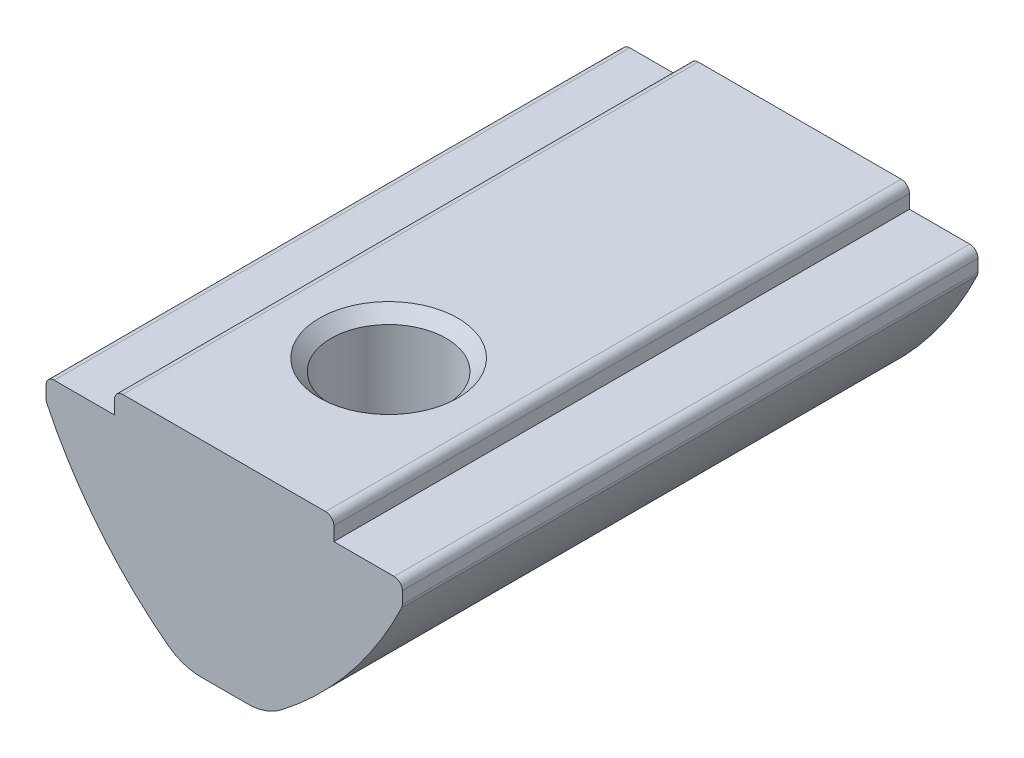
from build123d import *

# Parameters (mm, degrees)
EXTRUDE_1_DEPTH             = 10.5
FILLET_1_R                  = 0.3
FILLET_2_R                  = 2
HOLE_WIZARD_M52_D           = 4.2
HOLE_WIZARD_M52_CSINK_D     = 5.05
HOLE_WIZARD_M52_CSINK_ANGLE = 90


with BuildPart() as part:
    # Эскиз1 → Бобышка-Вытянуть1 (new body, symmetric)
    with BuildSketch(Plane.XY):
        with BuildLine():
            Line((-4, 0), (4, 0))
            Line((4, 0), (4, -0.8))
            Line((4, -0.8), (6.5, -0.8))
            Line((6.5, -0.8), (6.5, -1.6))
            ThreePointArc((6.5, -1.6), (4.386776199, -4.87777644), (1.5, -7.5))
            Line((1.5, -7.5), (-1.5, -7.5))
            ThreePointArc((-1.5, -7.5), (-4.386776199, -4.87777644), (-6.5, -1.6))
            Line((-6.5, -1.6), (-6.5, -0.8))
            Line((-6.5, -0.8), (-4, -0.8))
            Line((-4, -0.8), (-4, 0))
        make_face()
    extrude(amount=EXTRUDE_1_DEPTH, both=True)

    # Скругление1
    fillet_1_edges = [part.edges().sort_by_distance(p)[0] for p in [
        (6.5, -0.8, 0),
        (6.5, -1.6, 0),
        (-6.5, -1.6, 0),
        (-6.5, -0.8, 0),
        (-4, 0, 0),
        (4, 0, 0),
    ]]
    fillet(fillet_1_edges, radius=FILLET_1_R)

    # Скругление2
    fillet_2_edges = [part.edges().sort_by_distance(p)[0] for p in [
        (1.5, -7.5, 0),
        (-1.5, -7.5, 0),
    ]]
    fillet(fillet_2_edges, radius=FILLET_2_R)

    # Отверстие обработанное метчиком M52 (through all)
    with Locations(Plane(origin=(0, 0, 0), x_dir=(1, 0, 0), z_dir=(0, 1, 0))):
        with Locations((0, -4.5)):
            CounterSinkHole(HOLE_WIZARD_M52_D / 2, HOLE_WIZARD_M52_CSINK_D / 2, counter_sink_angle=HOLE_WIZARD_M52_CSINK_ANGLE)

    # Эскиз5 → Повернуть1 (revolve)
    with BuildSketch(Plane(origin=(0, 0, 0), x_dir=(0, 0, -1), z_dir=(1, 0, 0))):
        with BuildLine():
            Line((6.5, -4.3), (6.5, -8.3))
            ThreePointArc((6.5, -8.3), (4.5, -6.3), (6.5, -4.3))
        make_face()
    revolve(axis=Axis((0, -4.3, -6.5), (0, -1, 0)))


solid = part.part
